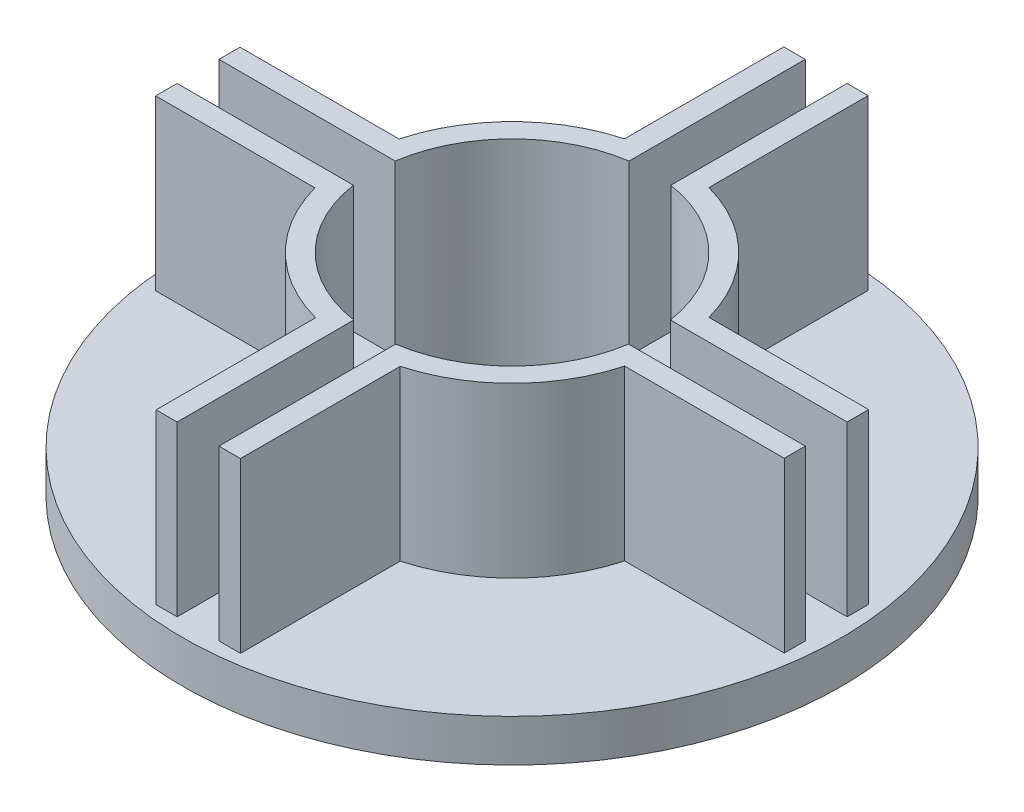
from build123d import *

# Parameters (mm, degrees)
SKETCH1_R           = 24.13
SKETCH1_R_2         = 21.43125
BOSS_EXTRUDE1_DEPTH = 25.4
SKETCH2_W           = 6.223
SKETCH2_H           = 31.914566101
CUT_EXTRUDE1_DEPTH  = 25.4
CIRPATTERN1_COUNT   = 4
SKETCH3_R           = 24.13
SKETCH3_R_2         = 21.43125
BOSS_EXTRUDE3_DEPTH = 3.175
SKETCH4_R           = 49.609375
SKETCH4_R_2         = 24.13
BOSS_EXTRUDE4_DEPTH = 3.175
BOSS_EXTRUDE5_DEPTH = 25.4
SKETCH11_R          = 21.43125
SKETCH11_R_2        = 20.955
BOSS_EXTRUDE6_DEPTH = 28.575
SKETCH14_R          = 49.609375
SKETCH14_R_2        = 20.955
BOSS_EXTRUDE7_DEPTH = 3.175
SKETCH15_W          = 94.553098484
SKETCH15_H          = 6.29591516
CUT_EXTRUDE8_DEPTH  = 25.4
SKETCH16_W          = 6.29591516
SKETCH16_H          = 94.553098484
CUT_EXTRUDE9_DEPTH  = 25.4


with BuildPart() as part:
    # Sketch1 → Boss-Extrude1 (new body)
    with BuildSketch(Plane(origin=(0, 0, 0), x_dir=(1, 0, 0), z_dir=(0, 1, 0))):
        Circle(SKETCH1_R)
        Circle(SKETCH1_R_2, mode=Mode.SUBTRACT)
    extrude(amount=BOSS_EXTRUDE1_DEPTH)

    # Sketch2 → Cut-Extrude1 (cut)
    with BuildSketch(Plane.XY):
        with Locations((0, 15.957283051)):
            Rectangle(SKETCH2_W, SKETCH2_H)
    cut_extrude1 = extrude(amount=-CUT_EXTRUDE1_DEPTH, mode=Mode.SUBTRACT)

    # CirPattern1: Cut-Extrude1 ×4 about axis
    cirpattern1_axis = Axis((0, 0, 0), (0, 1, 0))
    for i in range(1, CIRPATTERN1_COUNT):
        add(cut_extrude1.rotate(cirpattern1_axis, i * 360 / CIRPATTERN1_COUNT), mode=Mode.SUBTRACT)

    # Sketch3 → Boss-Extrude3 (add)
    with BuildSketch(Plane.XZ):
        Circle(SKETCH3_R)
        Circle(SKETCH3_R_2, mode=Mode.SUBTRACT)
    extrude(amount=BOSS_EXTRUDE3_DEPTH)

    # Sketch4 → Boss-Extrude4 (add)
    with BuildSketch(Plane(origin=(0, -3.175, 0), x_dir=(-1, 0, 0), z_dir=(0, -1, 0))):
        Circle(SKETCH4_R)
        Circle(SKETCH4_R_2, mode=Mode.SUBTRACT)
    extrude(amount=-BOSS_EXTRUDE4_DEPTH)

    # Sketch6 → Boss-Extrude5 (add)
    with BuildSketch(Plane(origin=(0, 0, 0), x_dir=(1, 0, 0), z_dir=(0, 1, 0))):
        Polygon((3.1115, 21.204175162), (3.1115, 23.929621576), (3.1115, 47.249506822), (6.35, 47.249506822), (6.35, 22.127823022), align=None)
        Polygon((-3.1115, 21.204175162), (-3.1115, 23.929621576), (-3.1115, 47.249506822), (-6.35, 47.249506822), (-6.35, 22.127823022), align=None)
        Polygon((21.267675162, 3.12091516), (23.993121576, 3.12091516), (47.313006822, 3.12091516), (47.313006822, 6.35941516), (22.191323022, 6.35941516), align=None)
        Polygon((47.313006822, -3.10208484), (23.993121576, -3.10208484), (21.267675162, -3.10208484), (22.191323022, -6.34058484), (47.313006822, -6.34058484), align=None)
        Polygon((3.18441516, -21.258260002), (3.18441516, -23.983706416), (3.18441516, -47.303591662), (6.42291516, -47.303591662), (6.42291516, -22.181907862), align=None)
        Polygon((-3.03858484, -47.303591662), (-3.03858484, -23.983706416), (-3.03858484, -21.258260002), (-6.27708484, -22.181907862), (-6.27708484, -47.303591662), align=None)
        Polygon((-21.194760002, -3.175), (-23.920206416, -3.175), (-47.240091662, -3.175), (-47.240091662, -6.4135), (-22.118407862, -6.4135), align=None)
        Polygon((-47.240091662, 3.048), (-23.920206416, 3.048), (-21.194760002, 3.048), (-22.118407862, 6.2865), (-47.240091662, 6.2865), align=None)
    extrude(amount=BOSS_EXTRUDE5_DEPTH)

    # Sketch11 → Boss-Extrude6 (add)
    with BuildSketch(Plane.XZ.offset(3.175)):
        Circle(SKETCH11_R)
        Circle(SKETCH11_R_2, mode=Mode.SUBTRACT)
    extrude(amount=-BOSS_EXTRUDE6_DEPTH)

    # Sketch14 → Boss-Extrude7 (add)
    with BuildSketch(Plane.XZ.offset(3.175)):
        Circle(SKETCH14_R)
        Circle(SKETCH14_R_2, mode=Mode.SUBTRACT)
    extrude(amount=BOSS_EXTRUDE7_DEPTH)

    # Sketch15 → Cut-Extrude8 (cut)
    with BuildSketch(Plane(origin=(0, 25.4, 0), x_dir=(1, 0, 0), z_dir=(0, 1, 0))):
        with Locations((0.03645758, -0.02704242)):
            Rectangle(SKETCH15_W, SKETCH15_H)
    extrude(amount=-CUT_EXTRUDE8_DEPTH, mode=Mode.SUBTRACT)

    # Sketch16 → Cut-Extrude9 (cut)
    with BuildSketch(Plane(origin=(0, 25.4, 0), x_dir=(1, 0, 0), z_dir=(0, 1, 0))):
        with Locations((0.03645758, -0.02704242)):
            Rectangle(SKETCH16_W, SKETCH16_H)
    extrude(amount=-CUT_EXTRUDE9_DEPTH, mode=Mode.SUBTRACT)


solid = part.part
